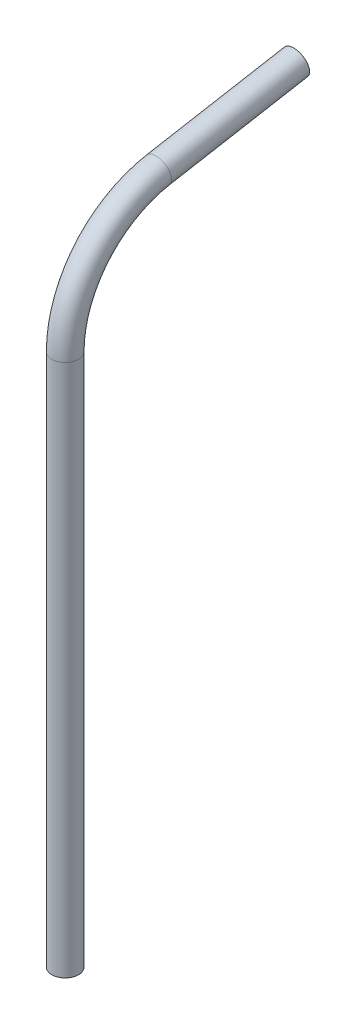
from build123d import *

# Parameters (mm, degrees)
SKETCH1_R           = 3.175
SKETCH1_R_2         = 2.667
BOSS_EXTRUDE1_DEPTH = 127
SKETCH3_R           = 3.175
SKETCH3_R_2         = 2.667


with BuildPart() as part:
    # Sketch1 → Boss-Extrude1 (new body)
    with BuildSketch(Plane(origin=(0, 0, 0), x_dir=(1, 0, 0), z_dir=(0, 1, 0))):
        Circle(SKETCH1_R)
        Circle(SKETCH1_R_2, mode=Mode.SUBTRACT)
    extrude(amount=BOSS_EXTRUDE1_DEPTH)

    # Sweep1: sweep along a path in Sketch2
    with BuildLine(Plane(origin=(0, 0, 0), x_dir=(0, 0, -1), z_dir=(1, 0, 0))) as sweep1_path:
        Line((55.012797254, 159.298316562), (22.166564651, 153.456678788))
        ThreePointArc((22.166564651, 153.456678788), (6.2740832, 144.25769713), (0, 127))
    # Sketch3 → Sweep1 (sweep)
    with BuildSketch(Plane(origin=(0, 127, 0), x_dir=(1, 0, 0), z_dir=(0, 1, 0))):
        Circle(SKETCH3_R)
        Circle(SKETCH3_R_2, mode=Mode.SUBTRACT)
    sweep(path=sweep1_path.line)


solid = part.part
